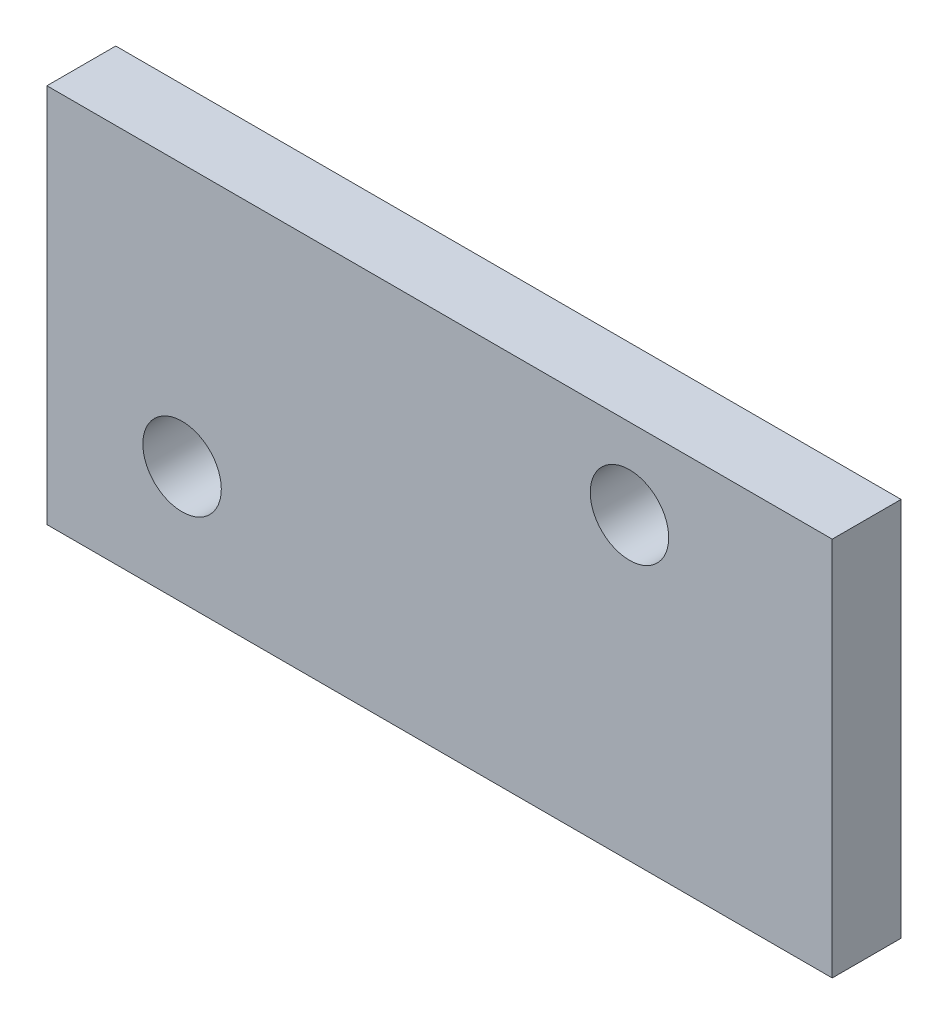
from build123d import *

# Parameters (mm, degrees)
SKETCH1_W           = 28.979443015
SKETCH1_H           = 14.025138193
SKETCH1_R           = 1.4478
BOSS_EXTRUDE1_DEPTH = 2.54


with BuildPart() as part:
    # Sketch1 → Boss-Extrude1 (new body)
    with BuildSketch(Plane.XY):
        with Locations((-190.771463543, 154.376414259)):
            Rectangle(SKETCH1_W, SKETCH1_H)
        with Locations((-183.764201867, 158.419196183)):
            Circle(SKETCH1_R, mode=Mode.SUBTRACT)
        with Locations((-200.274201867, 151.713596183)):
            Circle(SKETCH1_R, mode=Mode.SUBTRACT)
    extrude(amount=BOSS_EXTRUDE1_DEPTH)


solid = part.part
